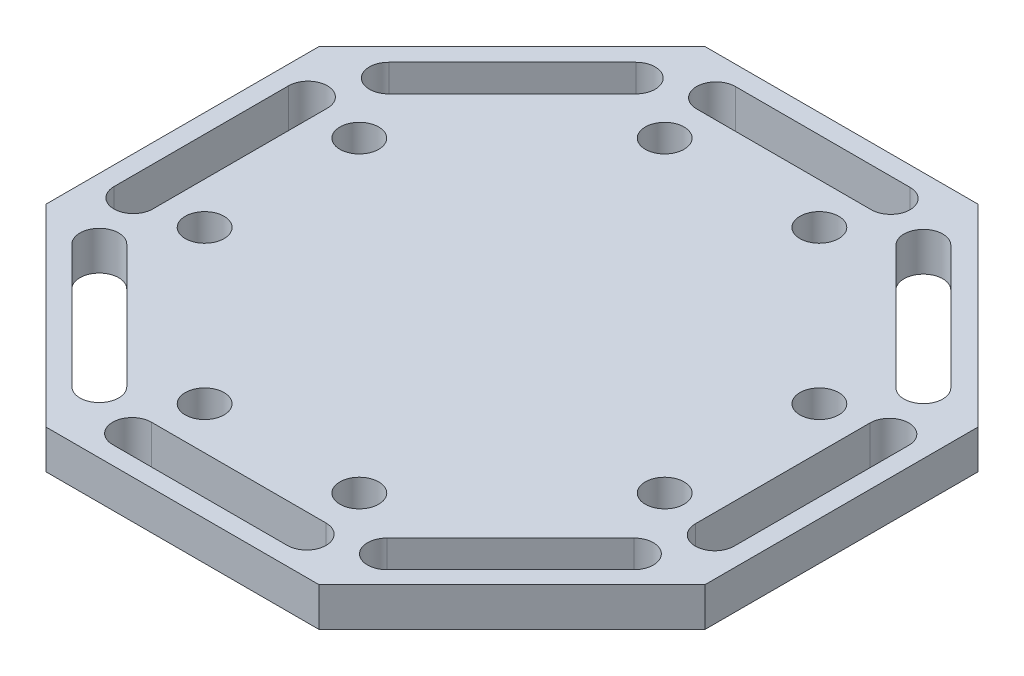
from build123d import *

# Parameters (mm, degrees)
SKETCH1_R           = 1.5
BOSS_EXTRUDE1_DEPTH = 3


with BuildPart() as part:
    # Sketch1 → Boss-Extrude1 (new body)
    with BuildSketch(Plane(origin=(0, 0, 0), x_dir=(1, 0, 0), z_dir=(0, 1, 0))):
        Polygon((10.55, -25.469953083), (25.469953083, -10.55), (25.469953083, 10.55), (10.55, 25.469953083), (-10.55, 25.469953083), (-25.469953083, 10.55), (-25.469953083, -10.55), (-10.55, -25.469953083), align=None)
        with Locations((-17.78, 5.978)):
            Circle(SKETCH1_R, mode=Mode.SUBTRACT)
        with Locations((-17.78, -5.978)):
            Circle(SKETCH1_R, mode=Mode.SUBTRACT)
        with Locations((5.978, 17.78)):
            Circle(SKETCH1_R, mode=Mode.SUBTRACT)
        with Locations((-5.978, 17.78)):
            Circle(SKETCH1_R, mode=Mode.SUBTRACT)
        with Locations((17.78, -5.978)):
            Circle(SKETCH1_R, mode=Mode.SUBTRACT)
        with Locations((17.78, 5.978)):
            Circle(SKETCH1_R, mode=Mode.SUBTRACT)
        with Locations((-5.978, -17.78)):
            Circle(SKETCH1_R, mode=Mode.SUBTRACT)
        with Locations((5.978, -17.78)):
            Circle(SKETCH1_R, mode=Mode.SUBTRACT)
        with BuildLine():
            Line((-6.7, 23.969953083), (6.8, 23.969953083))
            ThreePointArc((6.8, 23.969953083), (8.3, 22.469953083), (6.8, 20.969953083))
            Line((6.8, 20.969953083), (-6.7, 20.969953083))
            ThreePointArc((-6.7, 20.969953083), (-8.2, 22.469953083), (-6.7, 23.969953083))
        make_face(mode=Mode.SUBTRACT)
        with BuildLine():
            Line((10.125735931, 19.550966799), (19.671677477, 10.005025253))
            ThreePointArc((19.671677477, 10.005025253), (21.792997821, 10.005025253), (21.792997821, 12.126345597))
            Line((21.792997821, 12.126345597), (12.247056275, 21.672287143))
            ThreePointArc((12.247056275, 21.672287143), (10.125735931, 21.672287143), (10.125735931, 19.550966799))
        make_face(mode=Mode.SUBTRACT)
        with BuildLine():
            Line((21.019953083, 6.65), (21.019953083, -6.85))
            ThreePointArc((21.019953083, -6.85), (22.519953083, -8.35), (24.019953083, -6.85))
            Line((24.019953083, -6.85), (24.019953083, 6.65))
            ThreePointArc((24.019953083, 6.65), (22.519953083, 8.15), (21.019953083, 6.65))
        make_face(mode=Mode.SUBTRACT)
        with BuildLine():
            Line((19.600966799, -10.175735931), (10.055025253, -19.721677477))
            ThreePointArc((10.055025253, -19.721677477), (10.055025253, -21.842997821), (12.176345597, -21.842997821))
            Line((12.176345597, -21.842997821), (21.722287143, -12.297056275))
            ThreePointArc((21.722287143, -12.297056275), (21.722287143, -10.175735931), (19.600966799, -10.175735931))
        make_face(mode=Mode.SUBTRACT)
        with BuildLine():
            Line((6.7, -21.069953083), (-6.8, -21.069953083))
            ThreePointArc((-6.8, -21.069953083), (-8.3, -22.569953083), (-6.8, -24.069953083))
            Line((-6.8, -24.069953083), (6.7, -24.069953083))
            ThreePointArc((6.7, -24.069953083), (8.2, -22.569953083), (6.7, -21.069953083))
        make_face(mode=Mode.SUBTRACT)
        with BuildLine():
            Line((-10.125735931, -19.650966799), (-19.671677477, -10.105025253))
            ThreePointArc((-19.671677477, -10.105025253), (-21.792997821, -10.105025253), (-21.792997821, -12.226345597))
            Line((-21.792997821, -12.226345597), (-12.247056275, -21.772287143))
            ThreePointArc((-12.247056275, -21.772287143), (-10.125735931, -21.772287143), (-10.125735931, -19.650966799))
        make_face(mode=Mode.SUBTRACT)
        with BuildLine():
            Line((-21.019953083, -6.75), (-21.019953083, 6.75))
            ThreePointArc((-21.019953083, 6.75), (-22.519953083, 8.25), (-24.019953083, 6.75))
            Line((-24.019953083, 6.75), (-24.019953083, -6.75))
            ThreePointArc((-24.019953083, -6.75), (-22.519953083, -8.25), (-21.019953083, -6.75))
        make_face(mode=Mode.SUBTRACT)
        with BuildLine():
            Line((-19.600966799, 10.075735931), (-10.055025253, 19.621677477))
            ThreePointArc((-10.055025253, 19.621677477), (-10.055025253, 21.742997821), (-12.176345597, 21.742997821))
            Line((-12.176345597, 21.742997821), (-21.722287143, 12.197056275))
            ThreePointArc((-21.722287143, 12.197056275), (-21.722287143, 10.075735931), (-19.600966799, 10.075735931))
        make_face(mode=Mode.SUBTRACT)
    extrude(amount=BOSS_EXTRUDE1_DEPTH)


solid = part.part
